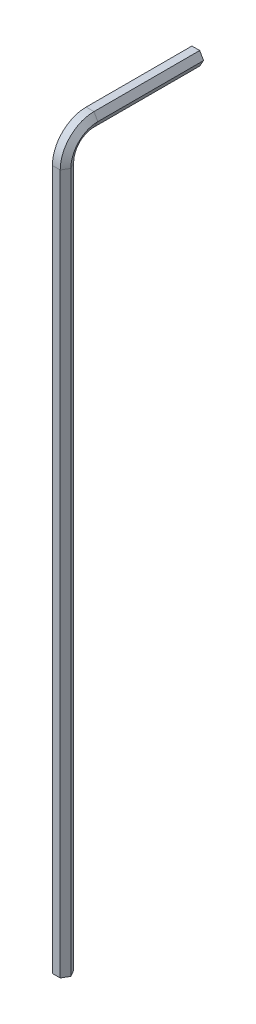
from build123d import *


with BuildPart() as part:
    # Sweep1: sweep along a path in Sketch2
    with BuildLine(Plane(origin=(0, 0, 0), x_dir=(0, 0, -1), z_dir=(1, 0, 0))) as sweep1_path:
        Line((0, 0), (0, 77.75))
        ThreePointArc((0, 77.75), (0.878679656, 79.871320344), (3, 80.75))
        Line((3, 80.75), (14.75, 80.75))
    # Sketch1 → Sweep1 (sweep)
    with BuildSketch(Plane(origin=(0, 0, 0), x_dir=(1, 0, 0), z_dir=(0, 1, 0))):
        Polygon((0.866025404, 0), (0.433012702, 0.75), (-0.433012702, 0.75), (-0.866025404, 0), (-0.433012702, -0.75), (0.433012702, -0.75), align=None)
    sweep(path=sweep1_path.line)


solid = part.part
